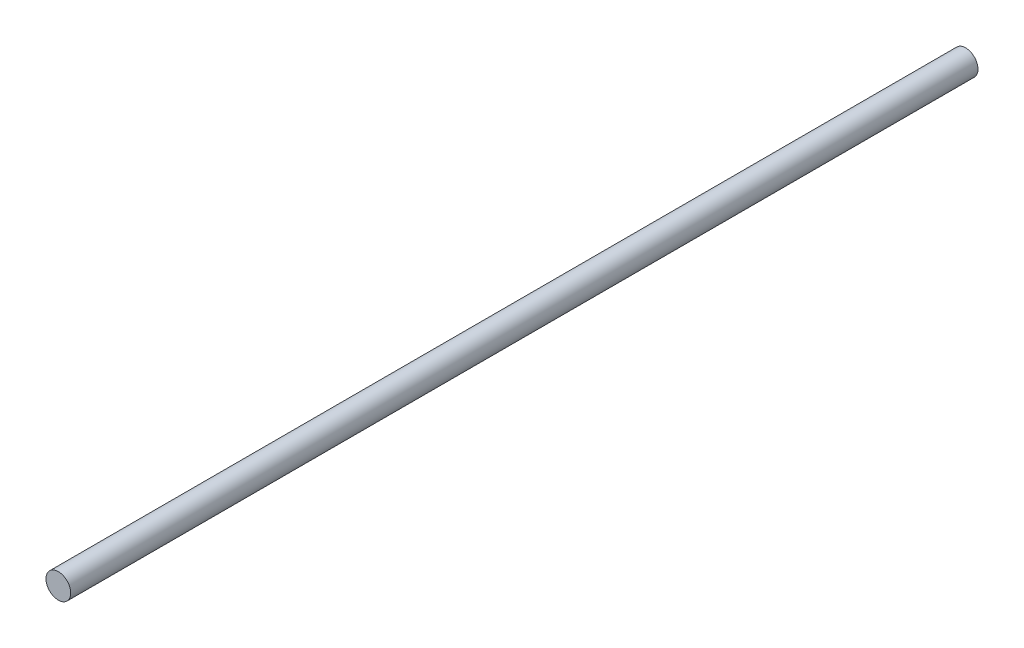
from build123d import *

# Parameters (mm, degrees)
SKETCH1_R           = 3
BOSS_EXTRUDE1_DEPTH = 220


with BuildPart() as part:
    # Sketch1 → Boss-Extrude1 (new body)
    with BuildSketch(Plane.XY):
        Circle(SKETCH1_R)
    extrude(amount=BOSS_EXTRUDE1_DEPTH)


solid = part.part
